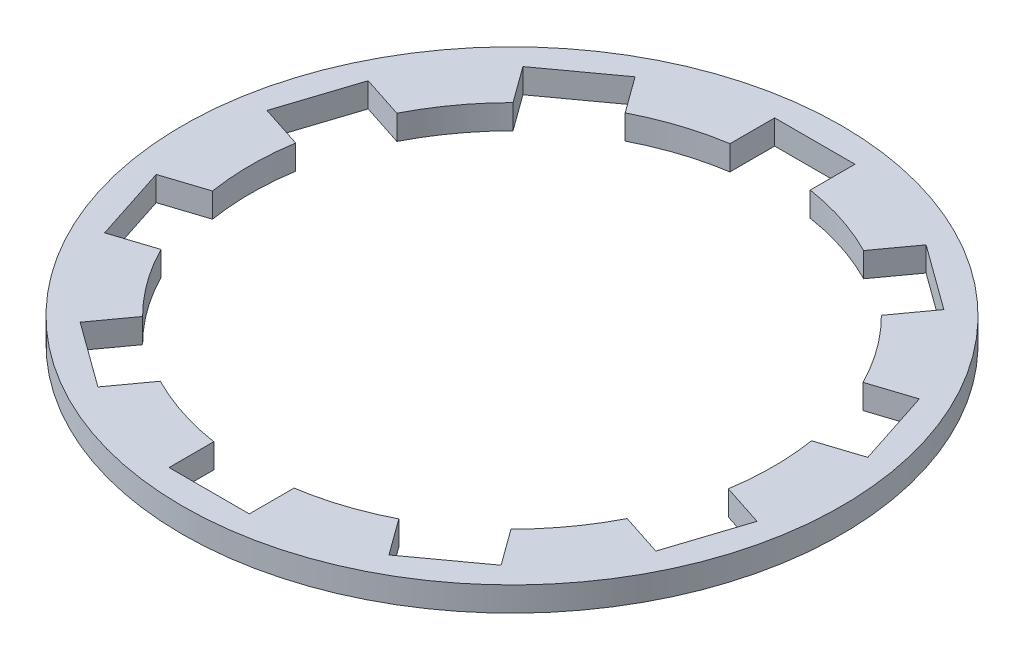
from build123d import *

# Parameters (mm, degrees)
SKETCH1_R           = 7.5311
SKETCH1_R_2         = 5.969
BOSS_EXTRUDE1_DEPTH = 0.5588
SKETCH2_W           = 1.834896806
SKETCH2_H           = 1.901806754
CUT_EXTRUDE1_DEPTH  = 1.5588
CIRPATTERN1_COUNT   = 10


with BuildPart() as part:
    # Sketch1 → Boss-Extrude1 (new body)
    with BuildSketch(Plane(origin=(0, 0, 0), x_dir=(1, 0, 0), z_dir=(0, 1, 0))):
        Circle(SKETCH1_R)
        Circle(SKETCH1_R_2, mode=Mode.SUBTRACT)
    extrude(amount=BOSS_EXTRUDE1_DEPTH)

    # Sketch2 → Cut-Extrude1 (cut, through all)
    with BuildSketch(Plane(origin=(0, 0.5588, 0), x_dir=(1, 0, 0), z_dir=(0, 1, 0))):
        with Locations((0, 5.969)):
            Rectangle(SKETCH2_W, SKETCH2_H)
    cut_extrude1 = extrude(amount=-CUT_EXTRUDE1_DEPTH, mode=Mode.SUBTRACT)

    # CirPattern1: Cut-Extrude1 ×10 about axis
    cirpattern1_axis = Axis((0, 0, 0), (0, 1, 0))
    for i in range(1, CIRPATTERN1_COUNT):
        add(cut_extrude1.rotate(cirpattern1_axis, i * 360 / CIRPATTERN1_COUNT), mode=Mode.SUBTRACT)


solid = part.part
